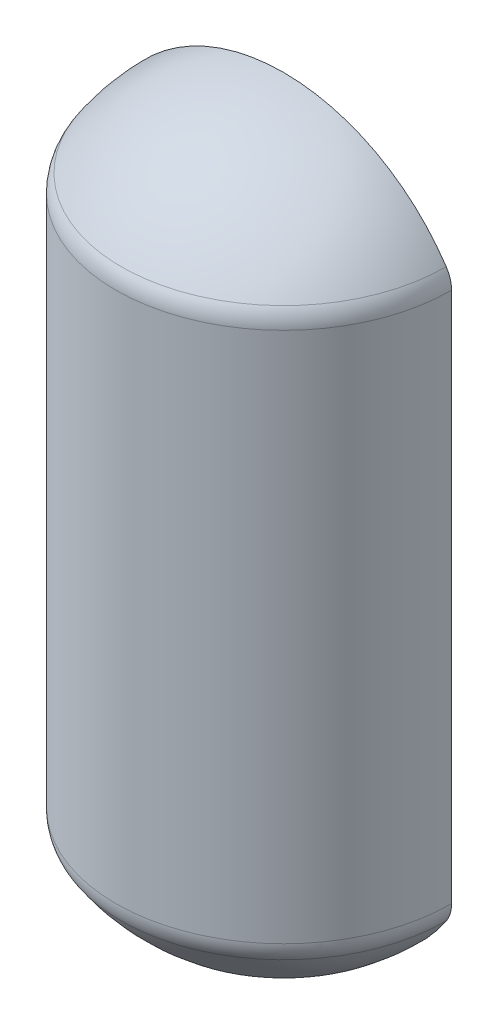
from build123d import *

# Parameters (mm, degrees)
REVOLVE2_ANGLE = 180
FILLET1_R      = 25.4


with BuildPart() as part:
    # Sketch1 → Revolve2 (revolve)
    with BuildSketch(Plane.XY):
        with BuildLine():
            ThreePointArc((0, 1196.825), (-75.121348346, 1177.071864985), (-130.81, 1122.922281449))
            Line((-130.81, 1122.922281449), (-130.81, 685.977718551))
            ThreePointArc((-130.81, 685.977718551), (-75.121348346, 631.828135015), (0, 612.075))
            Line((0, 612.075), (0, 608.9))
            ThreePointArc((0, 608.9), (-77.068833235, 629.282447395), (-133.985, 685.1))
            Line((-133.985, 685.1), (-133.985, 1123.8))
            ThreePointArc((-133.985, 1123.8), (-77.068833235, 1179.617552605), (0, 1200))
            Line((0, 1200), (0, 1196.825))
        make_face()
        with BuildLine():
            Line((0, 612.075), (0, 1196.825))
            ThreePointArc((0, 1196.825), (-75.121348346, 1177.071864985), (-130.81, 1122.922281449))
            Line((-130.81, 1122.922281449), (-130.81, 685.977718551))
            ThreePointArc((-130.81, 685.977718551), (-75.121348346, 631.828135015), (0, 612.075))
        make_face()
    revolve(axis=Axis((0, 0, 0), (0, 1, 0)), revolution_arc=REVOLVE2_ANGLE)

    # Fillet1
    fillet1_edges = [part.edges().sort_by_distance(p)[0] for p in [
        (0, 685.1, 133.985),
        (0, 1123.8, 133.985),
    ]]
    fillet(fillet1_edges, radius=FILLET1_R)


solid = part.part
